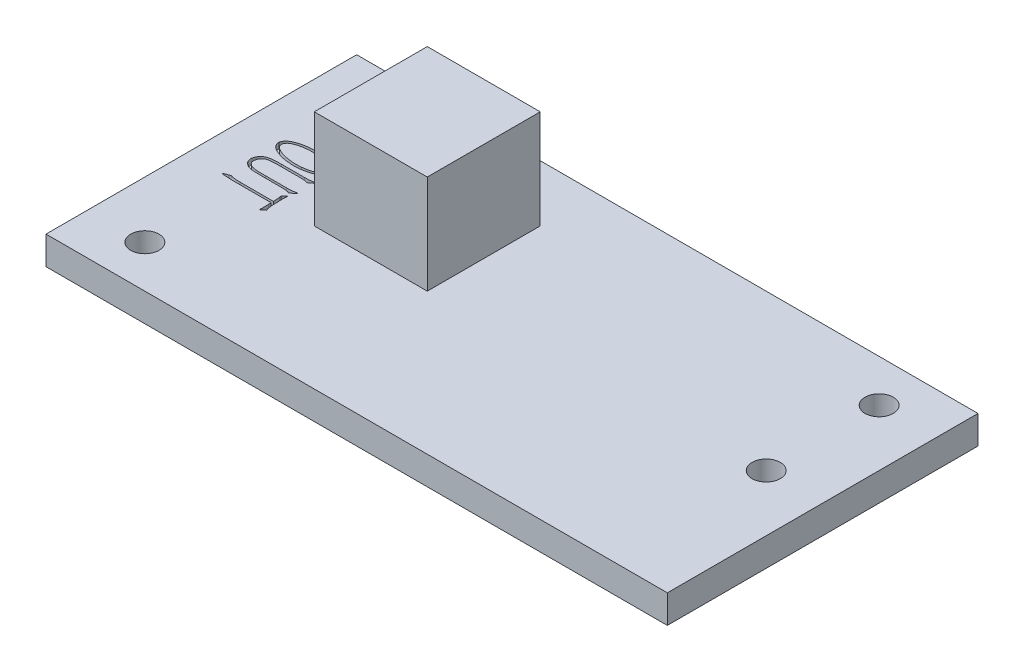
from build123d import *

# Parameters (mm, degrees)
SKETCH_1_W          = 22
SKETCH_1_H          = 11
EXTRUDE_1_DEPTH     = 1
EXTRUDE_START       = -1
SKETCH_2_W          = 4
SKETCH_2_H          = 4
EXTRUDE_2_DEPTH     = 4.5
SKETCH_3_R          = 0.5
CUT_EXTRUDE_1_DEPTH = 2
CUT_EXTRUDE_2_DEPTH = 0.2


with BuildPart() as part:
    # 草图1 → 凸台-拉伸1 (new body)
    with BuildSketch(Plane(origin=(0, 0, 0), x_dir=(1, 0, 0), z_dir=(0, 1, 0))):
        Rectangle(SKETCH_1_W, SKETCH_1_H)
    extrude(amount=EXTRUDE_1_DEPTH)

    # 草图2 → 凸台-拉伸2 (add)
    with BuildSketch(Plane(origin=(0, 1, 0), x_dir=(1, 0, 0), z_dir=(0, 1, 0)).offset(EXTRUDE_START)):
        with Locations((-4.5, 1.5)):
            Rectangle(SKETCH_2_W, SKETCH_2_H)
    extrude(amount=EXTRUDE_2_DEPTH)

    # 草图3 → 切除-拉伸1 (cut, through all)
    with BuildSketch(Plane(origin=(0, 1, 0), x_dir=(1, 0, 0), z_dir=(0, 1, 0))):
        with Locations((-9, 4)):
            Circle(SKETCH_3_R)
        with Locations((9, 4)):
            Circle(SKETCH_3_R)
        with Locations((9, 0)):
            Circle(SKETCH_3_R)
        with Locations((-9, -4)):
            Circle(SKETCH_3_R)
    extrude(amount=-CUT_EXTRUDE_1_DEPTH, mode=Mode.SUBTRACT)

    # 草图4 → 切除-拉伸2 (cut)
    with BuildSketch(Plane(origin=(0, 1, 0), x_dir=(1, 0, 0), z_dir=(0, 1, 0))):
        with BuildLine():
            add(Edge.make_bspline(
                [(-8.725593647, 1.81640353), (-8.698014484, 1.814651398), (-8.641185607, 1.811041003), (-8.553956656, 1.800825704), (-8.462129609, 1.787619798), (-8.367724499, 1.771143006), (-8.274214228, 1.750459174), (-8.186449422, 1.722463811), (-8.105957531, 1.688219236), (-8.034160516, 1.648738951), (-7.972592395, 1.606985839), (-7.921593134, 1.567395652), (-7.883165357, 1.52913753), (-7.857056968, 1.491969569), (-7.840713138, 1.456739202), (-7.829619465, 1.424296433), (-7.822301995, 1.393831449), (-7.82246764, 1.374077859), (-7.822546556, 1.364666901)],
                knots=[0, 0, 0, 0, 8.2891e-05, 0.000170804, 0.000263377, 0.000361188, 0.000458261, 0.000550447, 0.000637127, 0.000720286, 0.000795815, 0.000860108, 0.000913751, 0.000957846, 0.00099559, 0.001029822, 0.001060748, 0.001088888, 0.001088888, 0.001088888, 0.001088888], degree=3))
            add(Edge.make_bspline(
                [(-7.822546556, 1.364666901), (-7.824112344, 1.355643164), (-7.827441636, 1.336456252), (-7.8388999, 1.307279401), (-7.854604967, 1.275749798), (-7.875881563, 1.242664834), (-7.902945994, 1.2093862), (-7.937234409, 1.178003706), (-7.978393918, 1.149077635), (-8.042941108, 1.114203778), (-8.13157803, 1.076649782), (-8.225541826, 1.046501482), (-8.304863323, 1.027067566), (-8.368190238, 1.013588697), (-8.435120517, 1.002940964), (-8.528178359, 0.98961438), (-8.646693267, 0.979574853), (-8.741772263, 0.981173586), (-8.789092475, 0.981969266)],
                knots=[0, 0, 0, 0, 2.7414e-05, 5.829e-05, 9.3549e-05, 0.000133033, 0.000176031, 0.000221872, 0.000272007, 0.000326563, 0.00044167, 0.000560272, 0.000622185, 0.000686626, 0.000754446, 0.000825443, 0.000968672, 0.001110585, 0.001110585, 0.001110585, 0.001110585], degree=3))
            add(Edge.make_bspline(
                [(-8.789092475, 0.981969266), (-8.806856618, 0.982697155), (-8.843706004, 0.984207066), (-8.900554999, 0.989026955), (-8.96093486, 0.995972049), (-9.046250631, 1.007718997), (-9.155508054, 1.029066754), (-9.263668803, 1.058949216), (-9.348462296, 1.087976894), (-9.4085676, 1.113716971), (-9.465925968, 1.141323302), (-9.518702236, 1.172040521), (-9.566215732, 1.203904882), (-9.605611138, 1.238047323), (-9.637223007, 1.272570215), (-9.65970839, 1.308602523), (-9.674547533, 1.343465284), (-9.6854521, 1.375698531), (-9.690442344, 1.405707815), (-9.689857718, 1.424745782), (-9.689582567, 1.433705895)],
                knots=[0, 0, 0, 0, 5.3332e-05, 0.000110631, 0.000171106, 0.000235654, 0.000368963, 0.000504718, 0.000571973, 0.000637669, 0.000700756, 0.000762814, 0.000820736, 0.000872093, 0.00091888, 0.00096062, 0.000998785, 0.001032344, 0.001062542, 0.001089391, 0.001089391, 0.001089391, 0.001089391], degree=3))
            add(Edge.make_bspline(
                [(-9.689582567, 1.433705895), (-9.688443649, 1.4431362), (-9.686036537, 1.46306723), (-9.676268765, 1.493405611), (-9.660783021, 1.525198988), (-9.640632935, 1.558915951), (-9.613066268, 1.593023357), (-9.576853771, 1.625281507), (-9.532193991, 1.655525402), (-9.480109846, 1.683985153), (-9.421912141, 1.710402578), (-9.359167055, 1.734092408), (-9.292894936, 1.755443376), (-9.223921746, 1.773989664), (-9.153838304, 1.78887582), (-9.085124027, 1.801516506), (-9.018391846, 1.810070276), (-8.954077043, 1.814929149), (-8.892536545, 1.817901622), (-8.833990343, 1.819206992), (-8.778696147, 1.818952251), (-8.742920727, 1.817235165), (-8.725593647, 1.81640353)],
                knots=[0, 0, 0, 0, 2.8448e-05, 6.0125e-05, 9.5011e-05, 0.000134405, 0.000177734, 0.00022601, 0.000279323, 0.000339219, 0.000403869, 0.000470907, 0.000540315, 0.000612678, 0.000685066, 0.000755202, 0.000822228, 0.000886782, 0.000948648, 0.001007047, 0.001062451, 0.001114487, 0.001114487, 0.001114487, 0.001114487], degree=3))
        make_face()
        with BuildLine():
            add(Edge.make_bspline(
                [(-8.73155998, 1.73287487), (-8.745761704, 1.733672202), (-8.775710231, 1.735353611), (-8.82304619, 1.736174139), (-8.875049985, 1.735075143), (-8.951339526, 1.732516843), (-9.052163041, 1.723253961), (-9.153972929, 1.705093948), (-9.234997734, 1.685220019), (-9.293391505, 1.669057696), (-9.348197882, 1.649604173), (-9.398996424, 1.628637609), (-9.445048699, 1.606888886), (-9.483507826, 1.58217238), (-9.515969225, 1.557568984), (-9.539693409, 1.530179473), (-9.557858199, 1.503721591), (-9.570681519, 1.478252285), (-9.579943948, 1.454317168), (-9.582043862, 1.438318811), (-9.583040909, 1.430722729)],
                knots=[0, 0, 0, 0, 4.267e-05, 8.9982e-05, 0.000141981, 0.000198702, 0.000318966, 0.000445364, 0.000508519, 0.000569224, 0.000627046, 0.000682841, 0.00073411, 0.000779511, 0.000819844, 0.000855766, 0.00088768, 0.000915888, 0.000941229, 0.000964139, 0.000964139, 0.000964139, 0.000964139], degree=3))
            add(Edge.make_bspline(
                [(-9.583040909, 1.430722729), (-9.583501667, 1.422894105), (-9.584455403, 1.40668942), (-9.579566949, 1.381795206), (-9.570966698, 1.355745128), (-9.557092939, 1.328768073), (-9.537272561, 1.300811713), (-9.508647821, 1.274072414), (-9.472589008, 1.247398177), (-9.429634771, 1.221225676), (-9.381992546, 1.196070344), (-9.330969408, 1.173664846), (-9.278165167, 1.153043013), (-9.204556593, 1.129309579), (-9.109150895, 1.105413976), (-8.993339015, 1.084394719), (-8.879947955, 1.071626558), (-8.788068791, 1.064072619), (-8.714932615, 1.063010329), (-8.655953454, 1.064445412), (-8.591831714, 1.0676925), (-8.547443031, 1.071861228), (-8.524442997, 1.074021258)],
                knots=[0, 0, 0, 0, 2.3443e-05, 4.8525e-05, 7.5479e-05, 0.000105592, 0.000139181, 0.000177758, 0.000222505, 0.000273597, 0.000328498, 0.000384015, 0.00044068, 0.000498496, 0.000615915, 0.000735452, 0.000851322, 0.000958139, 0.001011843, 0.001070668, 0.001135109, 0.001204406, 0.001204406, 0.001204406, 0.001204406], degree=3))
            add(Edge.make_bspline(
                [(-8.524442997, 1.074021258), (-8.503537063, 1.076403337), (-8.462904656, 1.081033104), (-8.40441757, 1.090614155), (-8.349936111, 1.100716579), (-8.282833545, 1.115917366), (-8.202427123, 1.140592382), (-8.124450018, 1.169419102), (-8.066584357, 1.197673108), (-8.028618627, 1.219653195), (-7.997878142, 1.244840293), (-7.973544139, 1.271128303), (-7.955163242, 1.297859061), (-7.941517469, 1.323116171), (-7.932148236, 1.347170144), (-7.93007895, 1.363036639), (-7.929088214, 1.370633234)],
                knots=[0, 0, 0, 0, 6.3114e-05, 0.000122668, 0.000177749, 0.000229336, 0.000328977, 0.000429885, 0.000478296, 0.000522075, 0.000561146, 0.000597037, 0.000629193, 0.000658172, 0.000683113, 0.000706023, 0.000706023, 0.000706023, 0.000706023], degree=3))
            add(Edge.make_bspline(
                [(-7.929088214, 1.370633234), (-7.929629847, 1.378037073), (-7.930777644, 1.393726842), (-7.936165093, 1.418084144), (-7.947381156, 1.443282376), (-7.960546804, 1.471629616), (-7.982964212, 1.501640071), (-8.016901151, 1.53196385), (-8.06133757, 1.564526276), (-8.116249674, 1.598044697), (-8.1800535, 1.630816417), (-8.252782864, 1.658173783), (-8.332503672, 1.681379166), (-8.417743784, 1.697585093), (-8.503135978, 1.710678406), (-8.584515536, 1.721594853), (-8.660003255, 1.728978885), (-8.708393763, 1.73161356), (-8.73155998, 1.73287487)],
                knots=[0, 0, 0, 0, 2.2263e-05, 4.7178e-05, 7.4323e-05, 0.000104817, 0.000140787, 0.000185712, 0.000240859, 0.000305911, 0.000378526, 0.000455691, 0.000538641, 0.000627317, 0.000715739, 0.000797831, 0.00087361, 0.000943206, 0.000943206, 0.000943206, 0.000943206], degree=3))
        make_face(mode=Mode.SUBTRACT)
        with BuildLine():
            add(Edge.make_bspline(
                [(-7.952101212, 0.69942079), (-7.961762911, 0.701971405), (-7.979520296, 0.706659219), (-8.005711472, 0.71367662), (-8.033697274, 0.720462089), (-8.0612635, 0.724598681), (-8.08942077, 0.727876129), (-8.117271059, 0.73011452), (-8.150694546, 0.730571232), (-8.174845211, 0.730822587), (-8.187771359, 0.73095712)],
                knots=[0, 0, 0, 0, 2.9977e-05, 5.5096e-05, 8.1353e-05, 0.000116314, 0.000138622, 0.000166404, 0.000200082, 0.000238866, 0.000238866, 0.000238866, 0.000238866], degree=3))
            Line((-8.187771359, 0.73095712), (-8.97319646, 0.73095712))
            add(Edge.make_bspline(
                [(-8.97319646, 0.73095712), (-9.003456692, 0.730839593), (-9.06115264, 0.730615508), (-9.14373006, 0.727693206), (-9.218054979, 0.722558032), (-9.284254789, 0.716165752), (-9.342051841, 0.706986955), (-9.391115897, 0.693197691), (-9.432463289, 0.677027517), (-9.464808967, 0.654756585), (-9.49083792, 0.630158583), (-9.513130123, 0.603907221), (-9.532616293, 0.575869386), (-9.547442169, 0.545741087), (-9.559539582, 0.515543245), (-9.567967457, 0.48582466), (-9.573484539, 0.456993542), (-9.574178341, 0.438061716), (-9.574517576, 0.428804979)],
                knots=[0, 0, 0, 0, 9.0777e-05, 0.000173082, 0.000247836, 0.000314243, 0.000372604, 0.000423065, 0.000466993, 0.000505054, 0.00054003, 0.00057419, 0.000608233, 0.000642158, 0.000674684, 0.000705709, 0.000734717, 0.00076247, 0.00076247, 0.00076247, 0.00076247], degree=3))
            add(Edge.make_bspline(
                [(-9.574517576, 0.428804979), (-9.574430497, 0.415090693), (-9.5742619, 0.388538254), (-9.563774005, 0.351000458), (-9.547738543, 0.316878841), (-9.523023309, 0.288760988), (-9.495295307, 0.264661633), (-9.465849958, 0.243838122), (-9.435399358, 0.226654257), (-9.392979671, 0.20998043), (-9.339087882, 0.195324478), (-9.275001765, 0.183491476), (-9.213970222, 0.177345915), (-9.169389047, 0.17555764), (-9.138691111, 0.175680142), (-9.118093136, 0.175655151), (-9.09280722, 0.175664364), (-9.062691455, 0.1756612), (-9.027745788, 0.175662265), (-8.987970237, 0.175661917), (-8.943364796, 0.175662025), (-8.912112576, 0.175662008), (-8.895634133, 0.175662)],
                knots=[0, 0, 0, 0, 4.0967e-05, 7.9318e-05, 0.000115911, 0.000153124, 0.000190569, 0.000226041, 0.000261142, 0.000295171, 0.000362491, 0.000428358, 0.000490482, 0.00054635, 0.000562119, 0.000582575, 0.000608145, 0.000637976, 0.000672922, 0.000712982, 0.000757303, 0.000806738, 0.000806738, 0.000806738, 0.000806738], degree=3))
            Line((-8.895634133, 0.175662), (-8.156235028, 0.175662))
            add(Edge.make_bspline(
                [(-8.156235028, 0.175662), (-8.134072588, 0.175834733), (-8.093287359, 0.176152611), (-8.035716402, 0.178199544), (-7.983530142, 0.182096482), (-7.942237005, 0.187124388), (-7.911144337, 0.191567068), (-7.891514553, 0.194896089), (-7.875760545, 0.198292618), (-7.866578419, 0.200641874), (-7.862606219, 0.201658165)],
                knots=[0, 0, 0, 0, 6.6487e-05, 0.000122356, 0.00017279, 0.00022343, 0.000247116, 0.000267014, 0.000283146, 0.000295446, 0.000295446, 0.000295446, 0.000295446], degree=3))
            Line((-7.862606219, 0.201658165), (-7.816580223, 0.213164664))
            Line((-7.816580223, 0.213164664), (-7.788027059, 0.187168499))
            Line((-7.788027059, 0.187168499), (-7.960624544, 0.06059701))
            add(Edge.make_bspline(
                [(-7.960624544, 0.06059701), (-7.970233295, 0.064164068), (-7.987730816, 0.070659675), (-8.014584916, 0.078007459), (-8.044199559, 0.084789554), (-8.080733083, 0.08942651), (-8.123992059, 0.094807796), (-8.154793564, 0.095011267), (-8.170724693, 0.095116507)],
                knots=[0, 0, 0, 0, 3.0731e-05, 5.5962e-05, 8.3465e-05, 0.000121796, 0.000166365, 0.000214113, 0.000214113, 0.000214113, 0.000214113], degree=3))
            Line((-8.170724693, 0.095116507), (-8.305819516, 0.10108284))
            Line((-8.305819516, 0.10108284), (-8.990243125, 0.10108284))
            add(Edge.make_bspline(
                [(-8.990243125, 0.10108284), (-9.008000053, 0.101084777), (-9.041809243, 0.101088467), (-9.089682156, 0.101063849), (-9.132014096, 0.101141097), (-9.181467599, 0.100826394), (-9.241672389, 0.103109533), (-9.314747878, 0.109778171), (-9.388362112, 0.123566387), (-9.448418262, 0.141227636), (-9.493888549, 0.161285316), (-9.527474502, 0.178956545), (-9.559269749, 0.20132193), (-9.590703204, 0.225152293), (-9.618379897, 0.252566708), (-9.642008572, 0.281768992), (-9.660039467, 0.313152981), (-9.672795612, 0.346001155), (-9.680486259, 0.378962377), (-9.685298141, 0.410588589), (-9.687051105, 0.440665373), (-9.684739762, 0.459927585), (-9.683616234, 0.469290809)],
                knots=[0, 0, 0, 0, 5.3271e-05, 0.000101428, 0.000143618, 0.000180268, 0.000249781, 0.000324287, 0.00040018, 0.000474187, 0.000511401, 0.000549154, 0.000587807, 0.000627875, 0.000667353, 0.000704358, 0.00074025, 0.000775467, 0.00080968, 0.000841563, 0.000871422, 0.000899665, 0.000899665, 0.000899665, 0.000899665], degree=3))
            add(Edge.make_bspline(
                [(-9.683616234, 0.469290809), (-9.681485137, 0.483732584), (-9.677166588, 0.512998028), (-9.662477428, 0.556158121), (-9.641282268, 0.599018328), (-9.614014869, 0.64094268), (-9.581178856, 0.680168367), (-9.542614504, 0.713743259), (-9.498805911, 0.740412096), (-9.450492481, 0.7607159), (-9.398302071, 0.776083459), (-9.342905037, 0.788436988), (-9.284219501, 0.797308017), (-9.201617359, 0.804779985), (-9.095582165, 0.810290481), (-9.010137902, 0.811097401), (-8.967230127, 0.811502614)],
                knots=[0, 0, 0, 0, 4.3721e-05, 8.8598e-05, 0.000136056, 0.000186884, 0.000238286, 0.000289041, 0.000339547, 0.000391477, 0.000445807, 0.000502571, 0.000561638, 0.000623719, 0.000751325, 0.000880045, 0.000880045, 0.000880045, 0.000880045], degree=3))
            Line((-8.967230127, 0.811502614), (-8.150268695, 0.811502614))
            add(Edge.make_bspline(
                [(-8.150268695, 0.811502614), (-8.128389391, 0.811791551), (-8.087166198, 0.812335942), (-8.028301925, 0.815202209), (-7.975091237, 0.820348429), (-7.933707594, 0.824270373), (-7.903768761, 0.828321753), (-7.88513774, 0.831209081), (-7.869911799, 0.83415889), (-7.861034839, 0.836466895), (-7.857066053, 0.837498778)],
                knots=[0, 0, 0, 0, 6.5642e-05, 0.000123677, 0.00017673, 0.000226005, 0.000248365, 0.000267353, 0.000282564, 0.000294864, 0.000294864, 0.000294864, 0.000294864], degree=3))
            Line((-7.857066053, 0.837498778), (-7.811040057, 0.849005277))
            Line((-7.811040057, 0.849005277), (-7.782060726, 0.825992279))
            Line((-7.782060726, 0.825992279), (-7.952101212, 0.69942079))
        make_face()
        with BuildLine():
            Line((-7.97511421, -0.551804439), (-9.361434261, -0.551804439))
            Line((-9.361434261, -0.551804439), (-9.64611357, -0.537314774))
            add(Edge.make_bspline(
                [(-9.64611357, -0.537314774), (-9.659960813, -0.537144259), (-9.684805672, -0.536838321), (-9.71290588, -0.532021086), (-9.730435574, -0.527341436), (-9.737164026, -0.524053702), (-9.742903306, -0.52092877), (-9.741655809, -0.518338022), (-9.741148729, -0.517284942)],
                knots=[0, 0, 0, 0, 4.1373e-05, 7.4232e-05, 8.6233e-05, 9.424e-05, 9.877e-05, 0.000101873, 0.000101873, 0.000101873, 0.000101873], degree=3))
            add(Edge.make_bspline(
                [(-9.741148729, -0.517284942), (-9.740776157, -0.515985411), (-9.739891535, -0.512899845), (-9.736001248, -0.506970438), (-9.725631547, -0.499970635), (-9.708884006, -0.49410383), (-9.690430784, -0.487092171), (-9.677681484, -0.484081278), (-9.672109735, -0.482765445)],
                knots=[0, 0, 0, 0, 4.043e-06, 9.6e-06, 2.0851e-05, 4.0717e-05, 6.282e-05, 7.9978e-05, 7.9978e-05, 7.9978e-05, 7.9978e-05], degree=3))
            Line((-9.672109735, -0.482765445), (-9.568551244, -0.448245948))
            add(Edge.make_bspline(
                [(-9.568551244, -0.448245948), (-9.559475156, -0.444927168), (-9.543519858, -0.439092922), (-9.522586622, -0.432127498), (-9.507677326, -0.427978163), (-9.494509017, -0.427741879), (-9.480716149, -0.433150834), (-9.462811698, -0.440293907), (-9.441644402, -0.447225687), (-9.418474834, -0.453046992), (-9.39301623, -0.45658519), (-9.363327094, -0.460165892), (-9.326081315, -0.463536453), (-9.279522824, -0.467484922), (-9.223816352, -0.470450168), (-9.183868848, -0.470980029), (-9.162840611, -0.471258946)],
                knots=[0, 0, 0, 0, 2.8982e-05, 5.095e-05, 6.625e-05, 7.52e-05, 8.9895e-05, 0.000109997, 0.000133312, 0.000156568, 0.000181582, 0.000210338, 0.000246298, 0.000293757, 0.000350516, 0.000413602, 0.000413602, 0.000413602, 0.000413602], degree=3))
            Line((-9.162840611, -0.471258946), (-7.97767121, -0.471258946))
            add(Edge.make_bspline(
                [(-7.97767121, -0.471258946), (-7.977706725, -0.463157497), (-7.977772203, -0.448221514), (-7.979264486, -0.428927585), (-7.980357095, -0.410448544), (-7.982137958, -0.389001632), (-7.984666902, -0.359451991), (-7.988070884, -0.324826694), (-7.990397936, -0.290818389), (-7.993268509, -0.263596067), (-7.994558442, -0.246108755), (-7.99500723, -0.237719928), (-7.995144041, -0.235162632)],
                knots=[0, 0, 0, 0, 2.4295e-05, 4.4791e-05, 5.803e-05, 7.9831e-05, 0.000109347, 0.000147005, 0.000184201, 0.000211595, 0.000229115, 0.000236798, 0.000236798, 0.000236798, 0.000236798], degree=3))
            Line((-7.995144041, -0.235162632), (-8.003667374, -0.177630137))
            Line((-8.003667374, -0.177630137), (-7.920138714, -0.080037979))
            add(Edge.make_bspline(
                [(-7.920138714, -0.080037979), (-7.915646876, -0.07539736), (-7.908706601, -0.068227206), (-7.89733091, -0.061575901), (-7.889427245, -0.063486137), (-7.88348983, -0.067122962), (-7.879945005, -0.075301553), (-7.880028672, -0.081715822), (-7.880079051, -0.085578145)],
                knots=[0, 0, 0, 0, 1.9608e-05, 3.0297e-05, 3.6816e-05, 4.2962e-05, 5.0585e-05, 6.2123e-05, 6.2123e-05, 6.2123e-05, 6.2123e-05], degree=3))
            add(Edge.make_bspline(
                [(-7.880079051, -0.085578145), (-7.880553433, -0.087417719), (-7.882132356, -0.093540518), (-7.882082414, -0.107068197), (-7.88347524, -0.12816376), (-7.883213182, -0.14494809), (-7.883062217, -0.154617139)],
                knots=[0, 0, 0, 0, 5.686e-06, 1.8924e-05, 4.025e-05, 6.9229e-05, 6.9229e-05, 6.9229e-05, 6.9229e-05], degree=3))
            Line((-7.883062217, -0.154617139), (-7.885619217, -0.200643135))
            add(Edge.make_bspline(
                [(-7.885619217, -0.200643135), (-7.886112583, -0.202196835), (-7.88781754, -0.207566053), (-7.886348184, -0.219462479), (-7.887359034, -0.237990864), (-7.886259851, -0.252627916), (-7.885619217, -0.261158797)],
                knots=[0, 0, 0, 0, 4.859e-06, 1.6792e-05, 3.5117e-05, 6.0719e-05, 6.0719e-05, 6.0719e-05, 6.0719e-05], degree=3))
            Line((-7.885619217, -0.261158797), (-7.885619217, -0.321674459))
            Line((-7.885619217, -0.321674459), (-7.880079051, -0.471258946))
            Line((-7.880079051, -0.471258946), (-7.877095885, -0.591864103))
            add(Edge.make_bspline(
                [(-7.877095885, -0.591864103), (-7.876713073, -0.60225159), (-7.875823005, -0.626403366), (-7.869448883, -0.665444069), (-7.863299133, -0.709270893), (-7.859043156, -0.746088617), (-7.856695492, -0.772800112), (-7.853953701, -0.787646339), (-7.851964131, -0.79815161), (-7.849460525, -0.803124421), (-7.84854272, -0.804947418)],
                knots=[0, 0, 0, 0, 3.1157e-05, 7.2442e-05, 0.000118488, 0.00016395, 0.000183669, 0.000198803, 0.000209346, 0.000215447, 0.000215447, 0.000215447, 0.000215447], degree=3))
            Line((-7.84854272, -0.804947418), (-7.825529722, -0.86546308))
            Line((-7.825529722, -0.86546308), (-7.929088214, -0.948565573))
            add(Edge.make_bspline(
                [(-7.929088214, -0.948565573), (-7.9345311, -0.952242791), (-7.943194145, -0.958095551), (-7.954360949, -0.965193098), (-7.961751015, -0.96503082), (-7.966960674, -0.963829258), (-7.968262755, -0.958471786), (-7.968129559, -0.951739385), (-7.969572134, -0.941324008), (-7.969303294, -0.933220442), (-7.969147877, -0.928535741)],
                knots=[0, 0, 0, 0, 1.9975e-05, 3.1793e-05, 3.776e-05, 4.235e-05, 4.5991e-05, 5.2823e-05, 6.3086e-05, 7.715e-05, 7.715e-05, 7.715e-05, 7.715e-05], degree=3))
            Line((-7.969147877, -0.928535741), (-7.969147877, -0.86802008))
            Line((-7.969147877, -0.86802008), (-7.972131043, -0.652379764))
            add(Edge.make_bspline(
                [(-7.972131043, -0.652379764), (-7.971644194, -0.641584085), (-7.970766835, -0.622129032), (-7.970388826, -0.596420125), (-7.970385247, -0.577466492), (-7.971641049, -0.567283993), (-7.972131043, -0.563310938)],
                knots=[0, 0, 0, 0, 3.2414e-05, 5.8414e-05, 7.717e-05, 8.9171e-05, 8.9171e-05, 8.9171e-05, 8.9171e-05], degree=3))
            Line((-7.972131043, -0.563310938), (-7.97511421, -0.551804439))
        make_face()
    extrude(amount=-CUT_EXTRUDE_2_DEPTH, mode=Mode.SUBTRACT)


solid = part.part
